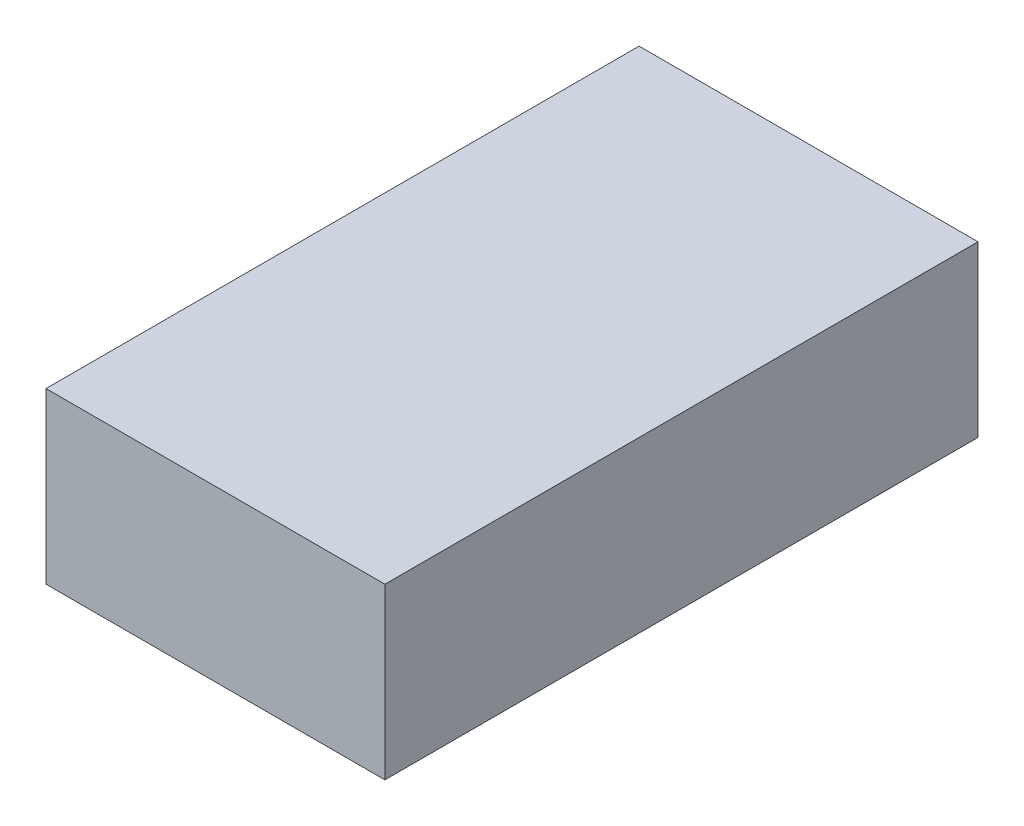
from build123d import *

# Parameters (mm, degrees)
SKETCH_1_W      = 160
SKETCH_1_H      = 80
EXTRUDE_1_DEPTH = 280


with BuildPart() as part:
    # ｽｹｯﾁ1 → ﾎﾞｽ - 押し出し1 (new body)
    with BuildSketch(Plane.XY):
        with Locations((80, 40)):
            Rectangle(SKETCH_1_W, SKETCH_1_H)
    extrude(amount=EXTRUDE_1_DEPTH)


solid = part.part
